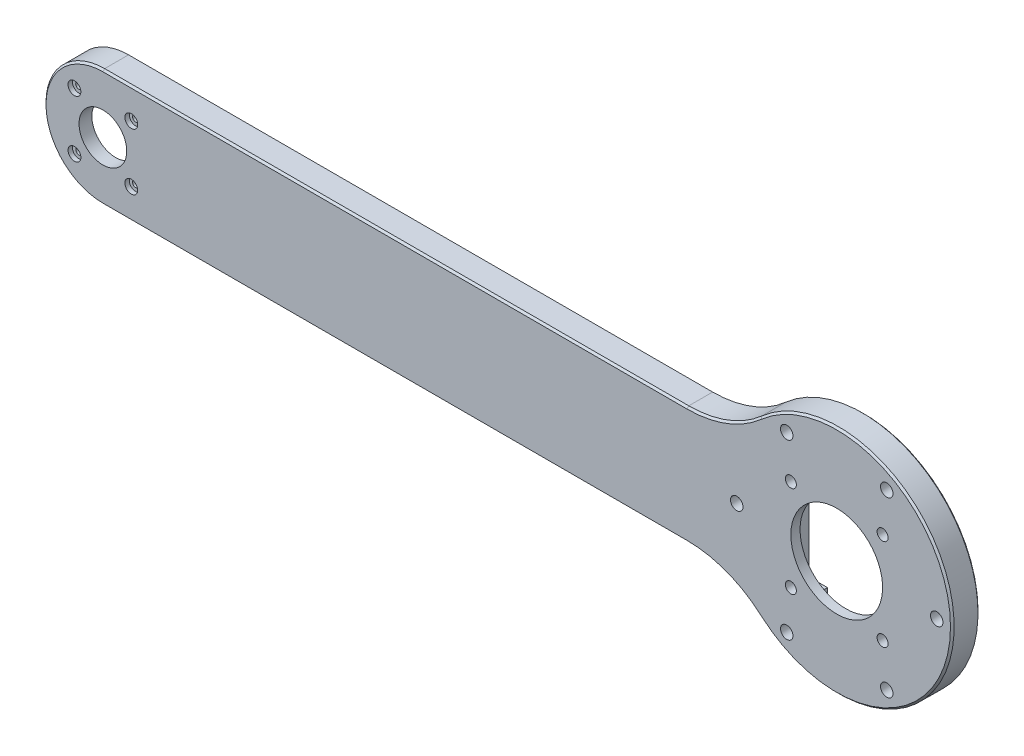
from build123d import *

# Parameters (mm, degrees)
BOSS_EXTRUDE1_DEPTH                      = 15
FILLET1_R                                = 60
SKETCH_2_R                               = 25
CUT_EXTRUDE_2_DEPTH                      = 16
CUT_EXTRUDE_START                        = -10
SKETCH_1_W                               = 60
SKETCH_1_H                               = 60
CUT_EXTRUDE_1_DEPTH                      = 10
SKETCH_3_W                               = 40
SKETCH_3_H                               = 33
CUT_EXTRUDE_3_DEPTH                      = 7
M7X1_0_1_D                               = 6
M7X1_0_1_DEPTH                           = 17
M7X1_0_1_TIP                             = 1.802581857
PATTERN_CIRCULAR_1_COUNT                 = 6
SKETCH5_R                                = 13
CUT_EXTRUDE2_DEPTH                       = 16
CUT_EXTRUDE1_START                       = -15
SKETCH4_W                                = 42
SKETCH4_H                                = 42
CUT_EXTRUDE1_DEPTH                       = 8
CUT_EXTRUDE3_START                       = -15
CUT_EXTRUDE3_DEPTH                       = 8
FILLET2_R                                = 3
CHAMFER1_SIZE                            = 1
CBORE_FOR_M3_PAN_HEAD_SCREW1_D           = 3.4
CBORE_FOR_M3_PAN_HEAD_SCREW1_CBORE_D     = 7
CBORE_FOR_M3_PAN_HEAD_SCREW1_CBORE_DEPTH = 2.4
FILLET6_R                                = 4


with BuildPart() as part:
    # Sketch2 → Boss-Extrude1 (new body)
    with BuildSketch(Plane.XY):
        with BuildLine():
            Line((-6.167694754, -49.941502997), (339.564451041, -49.941502997))
            ThreePointArc((339.564451041, -49.941502997), (456.832305246, -17.941502997), (339.564451041, 14.058497003))
            Line((339.564451041, 14.058497003), (-6.167694754, 14.058497003))
            ThreePointArc((-6.167694754, 14.058497003), (-38.167694754, -17.941502997), (-6.167694754, -49.941502997))
        make_face()
    extrude(amount=BOSS_EXTRUDE1_DEPTH)

    # Fillet1
    fillet1_edges = [part.edges().sort_by_distance(p)[0] for p in [
        (339.564451041, 14.058497003, 7.5),
        (339.564451041, -49.941502997, 7.5),
    ]]
    fillet(fillet1_edges, radius=FILLET1_R)

    # 草圖2 → 除料-伸長2 (cut, through all)
    with BuildSketch(Plane(origin=(0, 0, 0), x_dir=(-1, 0, 0), z_dir=(0, 0, -1))):
        with Locations((-393.832305246, -17.941502997)):
            Circle(SKETCH_2_R)
    extrude(amount=-CUT_EXTRUDE_2_DEPTH, mode=Mode.SUBTRACT)

    # 草圖1 → 除料-伸長1 (cut)
    with BuildSketch(Plane(origin=(0, 0, 0), x_dir=(-1, 0, 0), z_dir=(0, 0, -1)).offset(CUT_EXTRUDE_START)):
        with Locations((-393.832305246, -17.941502997)):
            Rectangle(SKETCH_1_W, SKETCH_1_H)
    extrude(amount=CUT_EXTRUDE_1_DEPTH, mode=Mode.SUBTRACT)

    # 草圖3 → 除料-伸長3 (cut)
    with BuildSketch(Plane(origin=(0, 0, 0), x_dir=(-1, 0, 0), z_dir=(0, 0, -1))):
        with Locations((-393.832305246, -64.441502997)):
            Rectangle(SKETCH_3_W, SKETCH_3_H)
    extrude(amount=-CUT_EXTRUDE_3_DEPTH, mode=Mode.SUBTRACT)

    # M7x1.0 螺紋孔1
    with Locations(Plane(origin=(0, 0, 10), x_dir=(-1, 0, 0), z_dir=(0, 0, -1))):
        with Locations((-368.832305246, 7.058497003), (-368.832305246, -42.941502997), (-418.832305246, -42.941502997), (-418.832305246, 7.058497003)):
            Hole(M7X1_0_1_D / 2, depth=M7X1_0_1_DEPTH)
            with Locations((0, 0, -(M7X1_0_1_DEPTH + M7X1_0_1_TIP / 2))):  # 118° drill point
                Cone(0, M7X1_0_1_D / 2, M7X1_0_1_TIP, mode=Mode.SUBTRACT)

    # 草圖8 → M8x1.25 螺紋孔1 (revolve, cut)
    with BuildSketch(Plane(origin=(448.332305246, -17.941502997, 15), x_dir=(0, -1, 0), z_dir=(1, 0, 0))):
        Polygon((0, 0), (0, 21.792926105), (3.4, 19.75), (3.4, 0), align=None)
    m8x1_25_1 = revolve(axis=Axis((448.332305246, -17.941502997, 21.35), (0, 0, -1)), mode=Mode.SUBTRACT)

    # 環狀複製排列1: M8x1.25 螺紋孔1 ×6 about axis
    pattern_circular_1_axis = Axis((393.832305246, -17.941502997, 0), (0, 0, 1))
    for i in range(1, PATTERN_CIRCULAR_1_COUNT):
        add(m8x1_25_1.rotate(pattern_circular_1_axis, i * 360 / PATTERN_CIRCULAR_1_COUNT), mode=Mode.SUBTRACT)

    # Sketch5 → Cut-Extrude2 (cut, through all)
    with BuildSketch(Plane.XY.offset(15)):
        with Locations((-6.167694754, -17.941502997)):
            Circle(SKETCH5_R)
    extrude(amount=-CUT_EXTRUDE2_DEPTH, mode=Mode.SUBTRACT)

    # Sketch4 → Cut-Extrude1 (cut)
    with BuildSketch(Plane.XY.offset(15).offset(CUT_EXTRUDE1_START)):
        with Locations((-6.167694754, -17.941502997)):
            Rectangle(SKETCH4_W, SKETCH4_H)
    extrude(amount=CUT_EXTRUDE1_DEPTH, mode=Mode.SUBTRACT)

    # Sketch8 → Cut-Extrude3 (cut)
    with BuildSketch(Plane.XY.offset(15).offset(CUT_EXTRUDE3_START)):
        with BuildLine():
            Line((-19.554255179, 3.058497003), (7.21886567, 3.058497003))
            ThreePointArc((7.21886567, 3.058497003), (-6.167694754, 11.058497003), (-19.554255179, 3.058497003))
        make_face()
    extrude(amount=CUT_EXTRUDE3_DEPTH, mode=Mode.SUBTRACT)

    # Fillet2
    fillet2_edges = [part.edges().sort_by_distance(p)[0] for p in [
        (-27.167694754, 3.058497003, 4),
        (-27.167694754, -38.941502997, 4),
        (14.832305246, -38.941502997, 4),
        (14.832305246, 3.058497003, 4),
        (7.21886567, 3.058497003, 4),
        (-19.554255179, 3.058497003, 4),
    ]]
    fillet(fillet2_edges, radius=FILLET2_R)

    # Chamfer1
    chamfer1_edges = [part.edges().sort_by_distance(p)[0] for p in [
        (153.012579622, 14.058497003, 0),
        (153.012579622, 14.058497003, 15),
        (362.287186837, -72.475029424, 0),
        (456.832305246, -17.941502997, 15),
        (333.492115408, 17.966238505, 0),
        (333.492115408, 17.966238505, 15),
        (333.492115408, -53.849244499, 0),
        (333.492115408, -53.849244499, 15),
        (-38.167694754, -17.941502997, 15),
        (448.365831673, 13.603615412, 0),
        (153.012579622, -49.941502997, 0),
        (-38.167694754, -17.941502997, 0),
        (153.012579622, -49.941502997, 15),
    ]]
    chamfer(chamfer1_edges, length=CHAMFER1_SIZE)

    # CBORE for M3 Pan Head Screw1 (through all)
    with Locations(Plane(origin=(0, 0, 15), x_dir=(-1, 0, 0), z_dir=(0, 0, 1))):
        with Locations((21.667694754, 2.441502997), (21.653333262, 33.427141505), (-9.317943754, 33.427141505), (-9.332305246, 2.441502997)):
            CounterBoreHole(CBORE_FOR_M3_PAN_HEAD_SCREW1_D / 2, CBORE_FOR_M3_PAN_HEAD_SCREW1_CBORE_D / 2, CBORE_FOR_M3_PAN_HEAD_SCREW1_CBORE_DEPTH)

    # Fillet6
    fillet6_edges = [part.edges().sort_by_distance(p)[0] for p in [
        (363.832305246, -47.941502997, 5),
        (363.832305246, 12.058497003, 5),
        (423.832305246, 12.058497003, 5),
        (423.832305246, -47.941502997, 5),
    ]]
    fillet(fillet6_edges, radius=FILLET6_R)


solid = part.part
